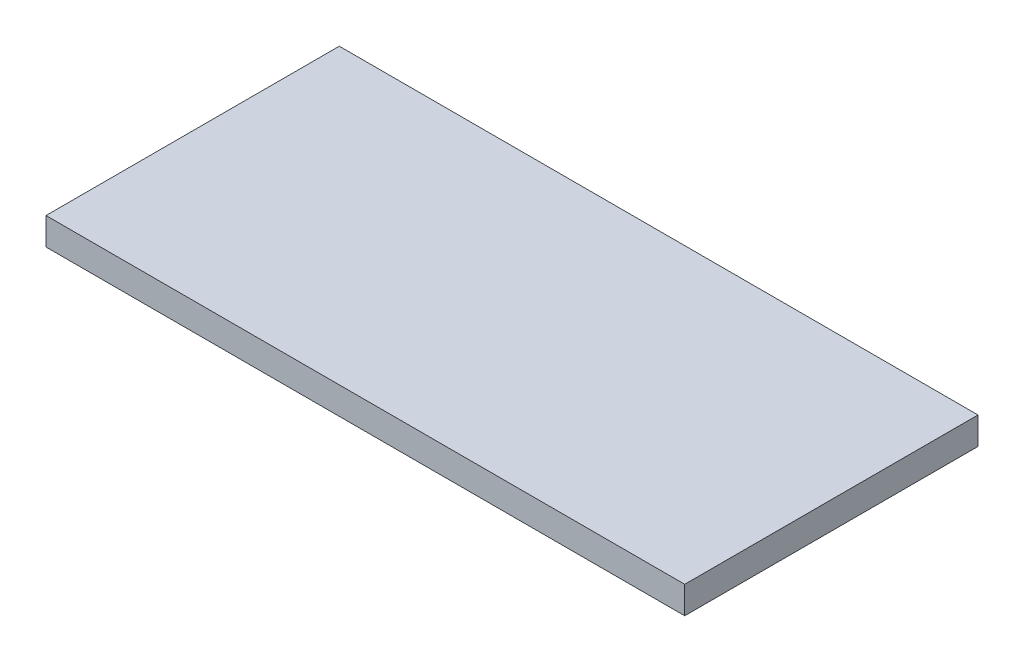
from build123d import *

# Parameters (mm, degrees)
SKETCH1_W           = 36.5
SKETCH1_H           = 16.76
BOSS_EXTRUDE1_DEPTH = 1.56


with BuildPart() as part:
    # Sketch1 → Boss-Extrude1 (new body)
    with BuildSketch(Plane(origin=(0, 0, 0), x_dir=(1, 0, 0), z_dir=(0, 1, 0))):
        with Locations((18.25, 8.38)):
            Rectangle(SKETCH1_W, SKETCH1_H)
    extrude(amount=BOSS_EXTRUDE1_DEPTH)


solid = part.part
